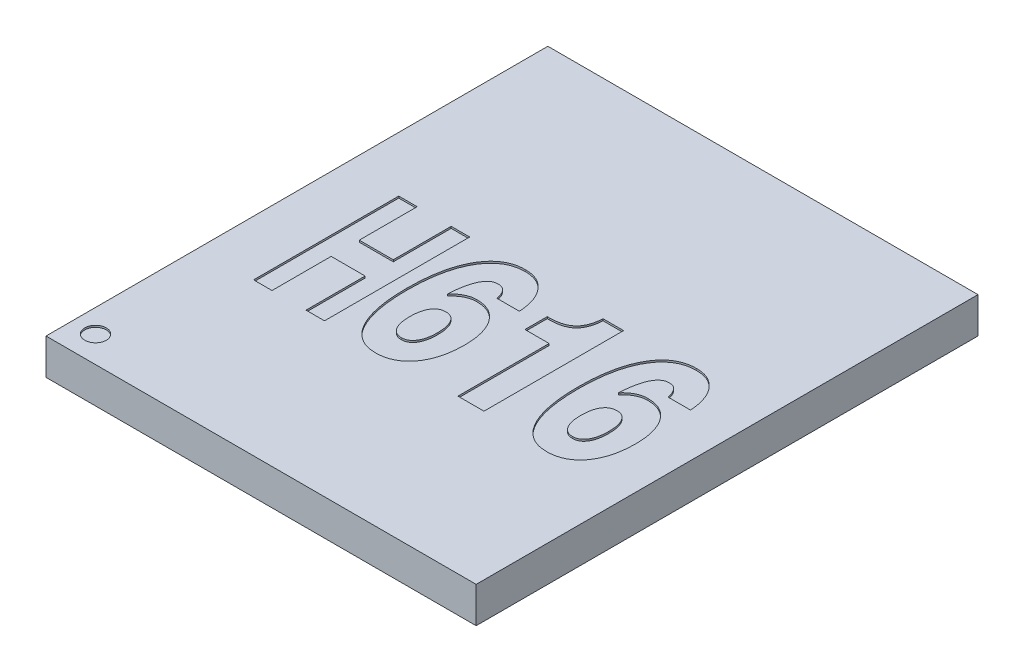
from build123d import *

# Parameters (mm, degrees)
SKETCH1_W           = 12
SKETCH1_H           = 14
BOSS_EXTRUDE1_DEPTH = 1
SKETCH2_R           = 0.175
BOSS_EXTRUDE2_DEPTH = 0.12
FILLET2_R           = 0.08
SKETCH3_R           = 0.3
CUT_EXTRUDE1_DEPTH  = 0.05


with BuildPart() as part:
    # Sketch1 → Boss-Extrude1 (new body)
    with BuildSketch(Plane(origin=(0, 0, 0), x_dir=(1, 0, 0), z_dir=(0, 1, 0))):
        Rectangle(SKETCH1_W, SKETCH1_H)
    extrude(amount=BOSS_EXTRUDE1_DEPTH)

    # Sketch2 → Boss-Extrude2 (add)
    with BuildSketch(Plane.XZ):
        with Locations((5.5, -6.525)):
            Circle(SKETCH2_R)
        with Locations((-5.5, -6.525)):
            Circle(SKETCH2_R)
        with Locations((4.85, -6.525)):
            Circle(SKETCH2_R)
        with Locations((4.2, -6.525)):
            Circle(SKETCH2_R)
        with Locations((3.55, -6.525)):
            Circle(SKETCH2_R)
        with Locations((2.9, -6.525)):
            Circle(SKETCH2_R)
        with Locations((2.25, -6.525)):
            Circle(SKETCH2_R)
        with Locations((1.6, -6.525)):
            Circle(SKETCH2_R)
        with Locations((0.95, -6.525)):
            Circle(SKETCH2_R)
        with Locations((0.3, -6.525)):
            Circle(SKETCH2_R)
        with Locations((-0.35, -6.525)):
            Circle(SKETCH2_R)
        with Locations((-1, -6.525)):
            Circle(SKETCH2_R)
        with Locations((-1.65, -6.525)):
            Circle(SKETCH2_R)
        with Locations((-2.3, -6.525)):
            Circle(SKETCH2_R)
        with Locations((-2.95, -6.525)):
            Circle(SKETCH2_R)
        with Locations((-3.6, -6.525)):
            Circle(SKETCH2_R)
        with Locations((-4.25, -6.525)):
            Circle(SKETCH2_R)
        with Locations((-4.9, -6.525)):
            Circle(SKETCH2_R)
        with Locations((4.85, -5.875)):
            Circle(SKETCH2_R)
        with Locations((4.2, -5.875)):
            Circle(SKETCH2_R)
        with Locations((3.55, -5.875)):
            Circle(SKETCH2_R)
        with Locations((2.9, -5.875)):
            Circle(SKETCH2_R)
        with Locations((2.25, -5.875)):
            Circle(SKETCH2_R)
        with Locations((1.6, -5.875)):
            Circle(SKETCH2_R)
        with Locations((0.95, -5.875)):
            Circle(SKETCH2_R)
        with Locations((0.3, -5.875)):
            Circle(SKETCH2_R)
        with Locations((-0.35, -5.875)):
            Circle(SKETCH2_R)
        with Locations((-1, -5.875)):
            Circle(SKETCH2_R)
        with Locations((-1.65, -5.875)):
            Circle(SKETCH2_R)
        with Locations((-2.3, -5.875)):
            Circle(SKETCH2_R)
        with Locations((-2.95, -5.875)):
            Circle(SKETCH2_R)
        with Locations((-3.6, -5.875)):
            Circle(SKETCH2_R)
        with Locations((-4.25, -5.875)):
            Circle(SKETCH2_R)
        with Locations((-4.9, -5.875)):
            Circle(SKETCH2_R)
        with Locations((-5.55, -5.875)):
            Circle(SKETCH2_R)
        with Locations((4.85, -5.225)):
            Circle(SKETCH2_R)
        with Locations((-4.9, -5.225)):
            Circle(SKETCH2_R)
        with Locations((-5.55, -5.225)):
            Circle(SKETCH2_R)
        with Locations((4.85, -4.575)):
            Circle(SKETCH2_R)
        with Locations((-4.9, -4.575)):
            Circle(SKETCH2_R)
        with Locations((-5.55, -4.575)):
            Circle(SKETCH2_R)
        with Locations((4.85, -3.925)):
            Circle(SKETCH2_R)
        with Locations((-4.9, -3.925)):
            Circle(SKETCH2_R)
        with Locations((-5.55, -3.925)):
            Circle(SKETCH2_R)
        with Locations((4.85, -3.275)):
            Circle(SKETCH2_R)
        with Locations((-4.9, -3.275)):
            Circle(SKETCH2_R)
        with Locations((-5.55, -3.275)):
            Circle(SKETCH2_R)
        with Locations((4.85, -2.625)):
            Circle(SKETCH2_R)
        with Locations((-4.9, -2.625)):
            Circle(SKETCH2_R)
        with Locations((-5.55, -2.625)):
            Circle(SKETCH2_R)
        with Locations((4.85, -1.975)):
            Circle(SKETCH2_R)
        with Locations((-4.9, -1.975)):
            Circle(SKETCH2_R)
        with Locations((-5.55, -1.975)):
            Circle(SKETCH2_R)
        with Locations((4.85, -1.325)):
            Circle(SKETCH2_R)
        with Locations((-4.9, -1.325)):
            Circle(SKETCH2_R)
        with Locations((-5.55, -1.325)):
            Circle(SKETCH2_R)
        with Locations((4.85, -0.675)):
            Circle(SKETCH2_R)
        with Locations((-4.9, -0.675)):
            Circle(SKETCH2_R)
        with Locations((-5.55, -0.675)):
            Circle(SKETCH2_R)
        with Locations((4.85, -0.025)):
            Circle(SKETCH2_R)
        with Locations((-4.9, -0.025)):
            Circle(SKETCH2_R)
        with Locations((-5.55, -0.025)):
            Circle(SKETCH2_R)
        with Locations((4.85, 0.625)):
            Circle(SKETCH2_R)
        with Locations((-4.9, 0.625)):
            Circle(SKETCH2_R)
        with Locations((-5.55, 0.625)):
            Circle(SKETCH2_R)
        with Locations((4.85, 1.275)):
            Circle(SKETCH2_R)
        with Locations((-4.9, 1.275)):
            Circle(SKETCH2_R)
        with Locations((-5.55, 1.275)):
            Circle(SKETCH2_R)
        with Locations((4.85, 1.925)):
            Circle(SKETCH2_R)
        with Locations((-4.9, 1.925)):
            Circle(SKETCH2_R)
        with Locations((-5.55, 1.925)):
            Circle(SKETCH2_R)
        with Locations((4.85, 2.575)):
            Circle(SKETCH2_R)
        with Locations((-4.9, 2.575)):
            Circle(SKETCH2_R)
        with Locations((-5.55, 2.575)):
            Circle(SKETCH2_R)
        with Locations((4.85, 3.225)):
            Circle(SKETCH2_R)
        with Locations((-4.9, 3.225)):
            Circle(SKETCH2_R)
        with Locations((-5.55, 3.225)):
            Circle(SKETCH2_R)
        with Locations((4.85, 3.875)):
            Circle(SKETCH2_R)
        with Locations((-4.9, 3.875)):
            Circle(SKETCH2_R)
        with Locations((-5.55, 3.875)):
            Circle(SKETCH2_R)
        with Locations((4.85, 4.525)):
            Circle(SKETCH2_R)
        with Locations((-4.9, 4.525)):
            Circle(SKETCH2_R)
        with Locations((-5.55, 4.525)):
            Circle(SKETCH2_R)
        with Locations((4.85, 5.175)):
            Circle(SKETCH2_R)
        with Locations((-4.9, 5.175)):
            Circle(SKETCH2_R)
        with Locations((-5.55, 5.175)):
            Circle(SKETCH2_R)
        with Locations((4.85, 5.825)):
            Circle(SKETCH2_R)
        with Locations((4.2, 5.825)):
            Circle(SKETCH2_R)
        with Locations((3.55, 5.825)):
            Circle(SKETCH2_R)
        with Locations((2.9, 5.825)):
            Circle(SKETCH2_R)
        with Locations((2.25, 5.825)):
            Circle(SKETCH2_R)
        with Locations((1.6, 5.825)):
            Circle(SKETCH2_R)
        with Locations((0.95, 5.825)):
            Circle(SKETCH2_R)
        with Locations((0.3, 5.825)):
            Circle(SKETCH2_R)
        with Locations((-0.35, 5.825)):
            Circle(SKETCH2_R)
        with Locations((-1, 5.825)):
            Circle(SKETCH2_R)
        with Locations((-1.65, 5.825)):
            Circle(SKETCH2_R)
        with Locations((-2.3, 5.825)):
            Circle(SKETCH2_R)
        with Locations((-2.95, 5.825)):
            Circle(SKETCH2_R)
        with Locations((-3.6, 5.825)):
            Circle(SKETCH2_R)
        with Locations((-4.25, 5.825)):
            Circle(SKETCH2_R)
        with Locations((-4.9, 5.825)):
            Circle(SKETCH2_R)
        with Locations((-5.55, 5.825)):
            Circle(SKETCH2_R)
        with Locations((4.85, 6.475)):
            Circle(SKETCH2_R)
        with Locations((4.2, 6.475)):
            Circle(SKETCH2_R)
        with Locations((3.55, 6.475)):
            Circle(SKETCH2_R)
        with Locations((2.9, 6.475)):
            Circle(SKETCH2_R)
        with Locations((2.25, 6.475)):
            Circle(SKETCH2_R)
        with Locations((1.6, 6.475)):
            Circle(SKETCH2_R)
        with Locations((0.95, 6.475)):
            Circle(SKETCH2_R)
        with Locations((0.3, 6.475)):
            Circle(SKETCH2_R)
        with Locations((-0.35, 6.475)):
            Circle(SKETCH2_R)
        with Locations((-1, 6.475)):
            Circle(SKETCH2_R)
        with Locations((-1.65, 6.475)):
            Circle(SKETCH2_R)
        with Locations((-2.3, 6.475)):
            Circle(SKETCH2_R)
        with Locations((-2.95, 6.475)):
            Circle(SKETCH2_R)
        with Locations((-3.6, 6.475)):
            Circle(SKETCH2_R)
        with Locations((-4.25, 6.475)):
            Circle(SKETCH2_R)
        with Locations((-4.9, 6.475)):
            Circle(SKETCH2_R)
        with Locations((-5.55, 6.475)):
            Circle(SKETCH2_R)
        with Locations((5.5, -5.875)):
            Circle(SKETCH2_R)
        with Locations((5.5, -5.225)):
            Circle(SKETCH2_R)
        with Locations((5.5, -4.575)):
            Circle(SKETCH2_R)
        with Locations((5.5, -3.925)):
            Circle(SKETCH2_R)
        with Locations((5.5, -3.275)):
            Circle(SKETCH2_R)
        with Locations((5.5, -2.625)):
            Circle(SKETCH2_R)
        with Locations((5.5, -1.975)):
            Circle(SKETCH2_R)
        with Locations((5.5, -1.325)):
            Circle(SKETCH2_R)
        with Locations((5.5, -0.675)):
            Circle(SKETCH2_R)
        with Locations((5.5, -0.025)):
            Circle(SKETCH2_R)
        with Locations((5.5, 0.625)):
            Circle(SKETCH2_R)
        with Locations((5.5, 1.275)):
            Circle(SKETCH2_R)
        with Locations((5.5, 1.925)):
            Circle(SKETCH2_R)
        with Locations((5.5, 2.575)):
            Circle(SKETCH2_R)
        with Locations((5.5, 3.225)):
            Circle(SKETCH2_R)
        with Locations((5.5, 3.875)):
            Circle(SKETCH2_R)
        with Locations((5.5, 4.525)):
            Circle(SKETCH2_R)
        with Locations((5.5, 5.175)):
            Circle(SKETCH2_R)
        with Locations((5.5, 5.825)):
            Circle(SKETCH2_R)
        with Locations((5.5, 6.475)):
            Circle(SKETCH2_R)
    extrude(amount=BOSS_EXTRUDE2_DEPTH)

    # Fillet2
    fillet2_edges = [part.edges().sort_by_distance(p)[0] for p in [
        (-0.525, -0.12, -5.875),
        (-1.175, -0.12, -5.875),
        (-1.825, -0.12, -5.875),
        (-2.475, -0.12, -5.875),
        (-3.125, -0.12, -5.875),
        (-3.775, -0.12, -5.875),
        (-4.425, -0.12, -5.875),
        (-5.075, -0.12, -5.875),
        (-5.725, -0.12, -5.875),
        (4.675, -0.12, -5.225),
        (-5.075, -0.12, -5.225),
        (-5.725, -0.12, -5.225),
        (4.675, -0.12, -4.575),
        (-5.075, -0.12, -4.575),
        (-5.725, -0.12, -4.575),
        (5.325, -0.12, -6.525),
        (4.675, -0.12, -3.925),
        (-5.075, -0.12, -3.925),
        (-5.725, -0.12, -3.925),
        (4.675, -0.12, -3.275),
        (-5.075, -0.12, -3.275),
        (-5.725, -0.12, -3.275),
        (4.675, -0.12, -2.625),
        (-5.075, -0.12, -2.625),
        (-5.725, -0.12, -2.625),
        (4.675, -0.12, -1.975),
        (-5.675, -0.12, -6.525),
        (-5.075, -0.12, -1.975),
        (-5.725, -0.12, -1.975),
        (4.675, -0.12, -1.325),
        (-5.075, -0.12, -1.325),
        (-5.725, -0.12, -1.325),
        (4.675, -0.12, -0.675),
        (-5.075, -0.12, -0.675),
        (-5.725, -0.12, -0.675),
        (4.675, -0.12, -0.025),
        (-5.075, -0.12, -0.025),
        (4.675, -0.12, -6.525),
        (-5.725, -0.12, -0.025),
        (4.675, -0.12, 0.625),
        (-5.075, -0.12, 0.625),
        (-5.725, -0.12, 0.625),
        (4.675, -0.12, 1.275),
        (-5.075, -0.12, 1.275),
        (-5.725, -0.12, 1.275),
        (4.675, -0.12, 1.925),
        (-5.075, -0.12, 1.925),
        (-5.725, -0.12, 1.925),
        (4.025, -0.12, -6.525),
        (4.675, -0.12, 2.575),
        (-5.075, -0.12, 2.575),
        (-5.725, -0.12, 2.575),
        (4.675, -0.12, 3.225),
        (-5.075, -0.12, 3.225),
        (-5.725, -0.12, 3.225),
        (4.675, -0.12, 3.875),
        (-5.075, -0.12, 3.875),
        (-5.725, -0.12, 3.875),
        (4.675, -0.12, 4.525),
        (3.375, -0.12, -6.525),
        (-5.075, -0.12, 4.525),
        (-5.725, -0.12, 4.525),
        (4.675, -0.12, 5.175),
        (-5.075, -0.12, 5.175),
        (-5.725, -0.12, 5.175),
        (4.675, -0.12, 5.825),
        (4.025, -0.12, 5.825),
        (3.375, -0.12, 5.825),
        (2.725, -0.12, 5.825),
        (2.075, -0.12, 5.825),
        (2.725, -0.12, -6.525),
        (1.425, -0.12, 5.825),
        (0.775, -0.12, 5.825),
        (0.125, -0.12, 5.825),
        (-0.525, -0.12, 5.825),
        (-1.175, -0.12, 5.825),
        (-1.825, -0.12, 5.825),
        (-2.475, -0.12, 5.825),
        (-3.125, -0.12, 5.825),
        (-3.775, -0.12, 5.825),
        (-4.425, -0.12, 5.825),
        (2.075, -0.12, -6.525),
        (-5.075, -0.12, 5.825),
        (-5.725, -0.12, 5.825),
        (4.675, -0.12, 6.475),
        (4.025, -0.12, 6.475),
        (3.375, -0.12, 6.475),
        (2.725, -0.12, 6.475),
        (2.075, -0.12, 6.475),
        (1.425, -0.12, 6.475),
        (0.775, -0.12, 6.475),
        (0.125, -0.12, 6.475),
        (1.425, -0.12, -6.525),
        (-0.525, -0.12, 6.475),
        (-1.175, -0.12, 6.475),
        (-1.825, -0.12, 6.475),
        (-2.475, -0.12, 6.475),
        (-3.125, -0.12, 6.475),
        (-3.775, -0.12, 6.475),
        (-4.425, -0.12, 6.475),
        (-5.075, -0.12, 6.475),
        (-5.725, -0.12, 6.475),
        (5.325, -0.12, -5.875),
        (0.775, -0.12, -6.525),
        (5.325, -0.12, -5.225),
        (5.325, -0.12, -4.575),
        (5.325, -0.12, -3.925),
        (5.325, -0.12, -3.275),
        (5.325, -0.12, -2.625),
        (5.325, -0.12, -1.975),
        (5.325, -0.12, -1.325),
        (5.325, -0.12, -0.675),
        (5.325, -0.12, -0.025),
        (5.325, -0.12, 0.625),
        (0.125, -0.12, -6.525),
        (5.325, -0.12, 1.275),
        (5.325, -0.12, 1.925),
        (5.325, -0.12, 2.575),
        (5.325, -0.12, 3.225),
        (5.325, -0.12, 3.875),
        (5.325, -0.12, 4.525),
        (5.325, -0.12, 5.175),
        (5.325, -0.12, 5.825),
        (5.325, -0.12, 6.475),
        (-0.525, -0.12, -6.525),
        (-1.175, -0.12, -6.525),
        (-1.825, -0.12, -6.525),
        (-2.475, -0.12, -6.525),
        (-3.125, -0.12, -6.525),
        (-3.775, -0.12, -6.525),
        (-4.425, -0.12, -6.525),
        (-5.075, -0.12, -6.525),
        (4.675, -0.12, -5.875),
        (4.025, -0.12, -5.875),
        (3.375, -0.12, -5.875),
        (2.725, -0.12, -5.875),
        (2.075, -0.12, -5.875),
        (1.425, -0.12, -5.875),
        (0.775, -0.12, -5.875),
        (0.125, -0.12, -5.875),
    ]]
    fillet(fillet2_edges, radius=FILLET2_R)

    # Sketch3 → Cut-Extrude1 (cut)
    with BuildSketch(Plane(origin=(0, 1, 0), x_dir=(1, 0, 0), z_dir=(0, 1, 0))):
        with Locations((-5.356190636, -6.262008845)):
            Circle(SKETCH3_R)
        Polygon((-2.482005753, -2.74830439), (-2.998297075, -2.74830439), (-2.998297075, -1.0990172), (-3.946365257, -1.0990172), (-3.946365257, -2.74830439), (-4.460983026, -2.74830439), (-4.460983026, 1.30169561), (-3.946365257, 1.30169561), (-3.946365257, -0.314120505), (-2.998297075, -0.314120505), (-2.998297075, 1.30169561), (-2.482005753, 1.30169561), align=None)
        with BuildLine():
            Line((0.006356665, 0.200468167), (-0.616720258, 0.200468167))
            add(Edge.make_bspline(
                [(-0.616720258, 0.200468167), (-0.623726124, 0.22956079), (-0.636944726, 0.284452476), (-0.664264545, 0.359922802), (-0.697450704, 0.423111864), (-0.73583534, 0.474996979), (-0.780671587, 0.514859659), (-0.830877476, 0.544269964), (-0.888044745, 0.5607696), (-0.927884783, 0.562850693), (-0.948541171, 0.563929705)],
                knots=[0, 0, 0, 0, 8.9732e-05, 0.000169305, 0.000240079, 0.000303199, 0.000361815, 0.000418872, 0.000476377, 0.000538296, 0.000538296, 0.000538296, 0.000538296], degree=3))
            add(Edge.make_bspline(
                [(-0.948541171, 0.563929705), (-0.965089948, 0.563036767), (-0.997710129, 0.56127665), (-1.045537101, 0.550648784), (-1.090790464, 0.531972468), (-1.132178291, 0.503952164), (-1.172785342, 0.471273279), (-1.208044654, 0.428361572), (-1.242494996, 0.380004119), (-1.272943756, 0.323291754), (-1.301466416, 0.259977266), (-1.326440857, 0.189091653), (-1.348050031, 0.110910549), (-1.367404793, 0.025610673), (-1.384510726, -0.066907543), (-1.39812802, -0.166814748), (-1.408499212, -0.274013409), (-1.413347572, -0.347954028), (-1.415848864, -0.386100343)],
                knots=[0, 0, 0, 0, 4.9655e-05, 9.7878e-05, 0.000146244, 0.000195526, 0.000247361, 0.000302008, 0.000361426, 0.000425334, 0.000494694, 0.000569624, 0.00065053, 0.000737913, 0.000831958, 0.000932696, 0.001040305, 0.001154986, 0.001154986, 0.001154986, 0.001154986], degree=3))
            add(Edge.make_bspline(
                [(-1.415848864, -0.386100343), (-1.395453838, -0.364027849), (-1.355653891, -0.320954401), (-1.290412315, -0.265379543), (-1.224554675, -0.217505618), (-1.156637551, -0.179218328), (-1.087133322, -0.148708646), (-1.015847854, -0.126874673), (-0.942846736, -0.113188252), (-0.893702322, -0.11177812), (-0.86903396, -0.111070295)],
                knots=[0, 0, 0, 0, 9.0083e-05, 0.000175793, 0.000256618, 0.000334003, 0.000409213, 0.000483892, 0.000557255, 0.000631195, 0.000631195, 0.000631195, 0.000631195], degree=3))
            add(Edge.make_bspline(
                [(-0.86903396, -0.111070295), (-0.834097284, -0.112262242), (-0.765770554, -0.114593369), (-0.665949305, -0.129882366), (-0.572026473, -0.156899745), (-0.483662332, -0.194381844), (-0.40113035, -0.242715119), (-0.32403409, -0.301601321), (-0.253681785, -0.37203055), (-0.188484903, -0.451784887), (-0.130442988, -0.540795508), (-0.080013868, -0.638218783), (-0.036779759, -0.743181363), (-0.002434002, -0.856347604), (0.025443623, -0.976902748), (0.044574111, -1.10548126), (0.055872028, -1.241815418), (0.057464138, -1.335297042), (0.058279742, -1.38318568)],
                knots=[0, 0, 0, 0, 0.000104811, 0.000204983, 0.000302048, 0.000397284, 0.000492182, 0.000588245, 0.000687492, 0.000790127, 0.000896787, 0.001005649, 0.001118795, 0.001236839, 0.001360038, 0.001489694, 0.001626464, 0.001770122, 0.001770122, 0.001770122, 0.001770122], degree=3))
            add(Edge.make_bspline(
                [(0.058279742, -1.38318568), (0.057718803, -1.437039298), (0.056628743, -1.541691733), (0.041895799, -1.694427622), (0.020817565, -1.838485934), (-0.009935284, -1.974262524), (-0.05043355, -2.100644304), (-0.099532641, -2.218706789), (-0.156532615, -2.328428163), (-0.223596866, -2.428211013), (-0.296511433, -2.518614701), (-0.378210725, -2.596468645), (-0.465373568, -2.663441941), (-0.560073587, -2.717225649), (-0.660251207, -2.760322814), (-0.767804251, -2.788505257), (-0.880999114, -2.808546032), (-0.95899432, -2.810216739), (-0.998841652, -2.811070295)],
                knots=[0, 0, 0, 0, 0.000161499, 0.000313838, 0.000459901, 0.00059806, 0.000730964, 0.000857527, 0.000981275, 0.001101208, 0.001217657, 0.001328973, 0.001438987, 0.00154656, 0.001654901, 0.001765121, 0.001879425, 0.001998821, 0.001998821, 0.001998821, 0.001998821], degree=3))
            add(Edge.make_bspline(
                [(-0.998841652, -2.811070295), (-1.042773607, -2.809601048), (-1.128641027, -2.806729323), (-1.253197248, -2.78162251), (-1.370174163, -2.74105961), (-1.478708495, -2.682365806), (-1.580302305, -2.608856589), (-1.673677538, -2.518430248), (-1.757641713, -2.41094284), (-1.835057911, -2.28890032), (-1.902816002, -2.15103792), (-1.96167315, -1.9988864), (-2.012067548, -1.83296744), (-2.051766429, -1.652967289), (-2.084522136, -1.459718927), (-2.106800668, -1.25219805), (-2.119453173, -1.030701425), (-2.121457708, -0.878304532), (-2.122489489, -0.799862362)],
                knots=[0, 0, 0, 0, 0.00013168, 0.000257377, 0.000379514, 0.000501829, 0.000626135, 0.000754659, 0.000890359, 0.001034408, 0.001187519, 0.001350382, 0.001523362, 0.00170719, 0.001902987, 0.002111112, 0.002332976, 0.002568303, 0.002568303, 0.002568303, 0.002568303], degree=3))
            add(Edge.make_bspline(
                [(-2.122489489, -0.799862362), (-2.121589893, -0.719251934), (-2.119840455, -0.562489302), (-2.105324233, -0.334192887), (-2.080406245, -0.119695624), (-2.045574834, 0.080708383), (-2.00253363, 0.267244719), (-1.948071084, 0.439559101), (-1.883264876, 0.597645341), (-1.809971902, 0.742216071), (-1.726383321, 0.870298092), (-1.635480084, 0.983178847), (-1.535023012, 1.077737363), (-1.426926948, 1.156385702), (-1.309941214, 1.216540254), (-1.185042772, 1.260345303), (-1.051769875, 1.285499813), (-0.960273234, 1.289045991), (-0.913655354, 1.290852782)],
                knots=[0, 0, 0, 0, 0.000241816, 0.000470258, 0.000685912, 0.000889317, 0.001080199, 0.001259806, 0.001430805, 0.001592272, 0.001745289, 0.001888853, 0.00202602, 0.002157962, 0.002288591, 0.00241919, 0.002553802, 0.00269363, 0.00269363, 0.00269363, 0.00269363], degree=3))
            add(Edge.make_bspline(
                [(-0.913655354, 1.290852782), (-0.881420548, 1.289908697), (-0.818271039, 1.288059188), (-0.725844799, 1.273779558), (-0.638142982, 1.251427989), (-0.555023084, 1.219407997), (-0.476610804, 1.177681793), (-0.403032616, 1.126525844), (-0.333898871, 1.066444478), (-0.27041733, 0.997587019), (-0.211714403, 0.921201331), (-0.160043512, 0.837657497), (-0.11501012, 0.747486846), (-0.077171342, 0.650723237), (-0.045290062, 0.54748771), (-0.021426425, 0.437496276), (-0.00328133, 0.321269883), (0.003094049, 0.241361485), (0.006356665, 0.200468167)],
                knots=[0, 0, 0, 0, 9.6667e-05, 0.000189375, 0.000279892, 0.00036773, 0.000455923, 0.000545717, 0.000636005, 0.000730151, 0.000826213, 0.000924595, 0.001024371, 0.001128173, 0.001235957, 0.001348154, 0.001465534, 0.001588566, 0.001588566, 0.001588566, 0.001588566], degree=3))
        make_face()
        with BuildLine():
            add(Edge.make_bspline(
                [(-1.002898142, -2.084147218), (-0.97421365, -2.082170489), (-0.918040656, -2.078299449), (-0.838862214, -2.045973507), (-0.771318381, -1.991504163), (-0.715410186, -1.917282649), (-0.669790559, -1.825598651), (-0.63955186, -1.716010829), (-0.619742882, -1.590784138), (-0.617766466, -1.5017237), (-0.616720258, -1.45457991)],
                knots=[0, 0, 0, 0, 8.5837e-05, 0.000168095, 0.000251847, 0.000343211, 0.000444801, 0.000557247, 0.000682894, 0.000824209, 0.000824209, 0.000824209, 0.000824209], degree=3))
            add(Edge.make_bspline(
                [(-0.616720258, -1.45457991), (-0.617914751, -1.408277563), (-0.620168133, -1.320929324), (-0.638072741, -1.197677536), (-0.670438238, -1.090974956), (-0.714398547, -1.000519179), (-0.770573659, -0.927954232), (-0.838564394, -0.875567706), (-0.917377971, -0.84265533), (-0.973912593, -0.83957346), (-1.002898142, -0.837993372)],
                knots=[0, 0, 0, 0, 0.000138884, 0.000262001, 0.000372349, 0.000472126, 0.000562213, 0.000644969, 0.000727227, 0.000813774, 0.000813774, 0.000813774, 0.000813774], degree=3))
            add(Edge.make_bspline(
                [(-1.002898142, -0.837993372), (-1.032971681, -0.839511366), (-1.091106113, -0.842445765), (-1.171973677, -0.875541914), (-1.241614271, -0.927613353), (-1.298693214, -1.000304369), (-1.342983584, -1.091074663), (-1.374096236, -1.199187144), (-1.392123782, -1.323898648), (-1.39437658, -1.412599629), (-1.395566412, -1.459447699)],
                knots=[0, 0, 0, 0, 8.9772e-05, 0.000173537, 0.000257587, 0.000348181, 0.000447957, 0.000558847, 0.00068437, 0.000824875, 0.000824875, 0.000824875, 0.000824875], degree=3))
            add(Edge.make_bspline(
                [(-1.395566412, -1.459447699), (-1.394470988, -1.506037978), (-1.392396581, -1.594266124), (-1.373093981, -1.718653569), (-1.341225477, -1.827250636), (-1.296410516, -1.919029634), (-1.239213894, -1.992794077), (-1.169970837, -2.045693392), (-1.089707798, -2.078585791), (-1.032419207, -2.082255962), (-1.002898142, -2.084147218)],
                knots=[0, 0, 0, 0, 0.000139694, 0.000264539, 0.000376439, 0.00047803, 0.000569257, 0.000653796, 0.000736806, 0.000825059, 0.000825059, 0.000825059, 0.000825059], degree=3))
        make_face(mode=Mode.SUBTRACT)
        with BuildLine():
            Line((1.198510511, -2.707224141), (1.198510511, -0.162993372))
            Line((1.198510511, -0.162993372), (0.523510511, -0.162993372))
            Line((0.523510511, -0.162993372), (0.523510511, 0.460083551))
            Line((0.523510511, 0.460083551), (0.582735271, 0.460083551))
            add(Edge.make_bspline(
                [(0.582735271, 0.460083551), (0.613312573, 0.460457396), (0.672420924, 0.461180069), (0.758133904, 0.469367911), (0.837559582, 0.483114448), (0.911266311, 0.501548224), (0.9790309, 0.525858207), (1.040693278, 0.555895028), (1.096704359, 0.590683997), (1.145758766, 0.632188086), (1.190610776, 0.678518306), (1.22802144, 0.73300871), (1.263062128, 0.792344489), (1.290688718, 0.859257901), (1.314379718, 0.931918069), (1.333181218, 1.011098939), (1.345572687, 1.096949341), (1.350786658, 1.156418761), (1.353468444, 1.187006628)],
                knots=[0, 0, 0, 0, 9.1709e-05, 0.000177281, 0.000257975, 0.000333339, 0.00040494, 0.000473518, 0.000538791, 0.000602155, 0.000665856, 0.000731591, 0.000799919, 0.000872252, 0.000948194, 0.001029072, 0.001116043, 0.001208153, 0.001208153, 0.001208153, 0.001208153], degree=3))
            Line((1.353468444, 1.187006628), (1.925433588, 1.187006628))
            Line((1.925433588, 1.187006628), (1.925433588, -2.707224141))
            Line((1.925433588, -2.707224141), (1.198510511, -2.707224141))
        make_face()
        with BuildLine():
            Line((4.779125896, 0.200468167), (4.156048973, 0.200468167))
            add(Edge.make_bspline(
                [(4.156048973, 0.200468167), (4.149043107, 0.22956079), (4.135824505, 0.284452476), (4.108504686, 0.359922802), (4.075318527, 0.423111864), (4.036933891, 0.474996979), (3.992097644, 0.514859659), (3.941891754, 0.544269964), (3.884724486, 0.5607696), (3.844884448, 0.562850693), (3.82422806, 0.563929705)],
                knots=[0, 0, 0, 0, 8.9732e-05, 0.000169305, 0.000240079, 0.000303199, 0.000361815, 0.000418872, 0.000476377, 0.000538296, 0.000538296, 0.000538296, 0.000538296], degree=3))
            add(Edge.make_bspline(
                [(3.82422806, 0.563929705), (3.807679283, 0.563036767), (3.775059102, 0.56127665), (3.72723213, 0.550648784), (3.681978766, 0.531972468), (3.64059094, 0.503952164), (3.599983888, 0.471273279), (3.564724577, 0.428361572), (3.530274235, 0.380004119), (3.499825474, 0.323291754), (3.471302815, 0.259977266), (3.446328373, 0.189091653), (3.424719199, 0.110910549), (3.405364437, 0.025610673), (3.388258505, -0.066907543), (3.374641211, -0.166814748), (3.364270019, -0.274013409), (3.359421659, -0.347954028), (3.356920367, -0.386100343)],
                knots=[0, 0, 0, 0, 4.9655e-05, 9.7878e-05, 0.000146244, 0.000195526, 0.000247361, 0.000302008, 0.000361426, 0.000425334, 0.000494694, 0.000569624, 0.00065053, 0.000737913, 0.000831958, 0.000932696, 0.001040305, 0.001154986, 0.001154986, 0.001154986, 0.001154986], degree=3))
            add(Edge.make_bspline(
                [(3.356920367, -0.386100343), (3.377315393, -0.364027849), (3.417115339, -0.320954401), (3.482356916, -0.265379543), (3.548214556, -0.217505618), (3.61613168, -0.179218328), (3.685635909, -0.148708646), (3.756921377, -0.126874673), (3.829922494, -0.113188252), (3.879066909, -0.11177812), (3.903735271, -0.111070295)],
                knots=[0, 0, 0, 0, 9.0083e-05, 0.000175793, 0.000256618, 0.000334003, 0.000409213, 0.000483892, 0.000557255, 0.000631195, 0.000631195, 0.000631195, 0.000631195], degree=3))
            add(Edge.make_bspline(
                [(3.903735271, -0.111070295), (3.938671947, -0.112262242), (4.006998677, -0.114593369), (4.106819926, -0.129882366), (4.200742758, -0.156899745), (4.289106899, -0.194381844), (4.371638881, -0.242715119), (4.448735141, -0.301601321), (4.519087446, -0.37203055), (4.584284328, -0.451784887), (4.642326242, -0.540795508), (4.692755363, -0.638218783), (4.735989472, -0.743181363), (4.770335228, -0.856347604), (4.798212854, -0.976902748), (4.817343342, -1.10548126), (4.828641259, -1.241815418), (4.830233369, -1.335297042), (4.831048973, -1.38318568)],
                knots=[0, 0, 0, 0, 0.000104811, 0.000204983, 0.000302048, 0.000397284, 0.000492182, 0.000588245, 0.000687492, 0.000790127, 0.000896787, 0.001005649, 0.001118795, 0.001236839, 0.001360038, 0.001489694, 0.001626464, 0.001770122, 0.001770122, 0.001770122, 0.001770122], degree=3))
            add(Edge.make_bspline(
                [(4.831048973, -1.38318568), (4.830488034, -1.437039298), (4.829397974, -1.541691733), (4.81466503, -1.694427622), (4.793586796, -1.838485934), (4.762833947, -1.974262524), (4.72233568, -2.100644304), (4.673236589, -2.218706789), (4.616236615, -2.328428163), (4.549172364, -2.428211013), (4.476257798, -2.518614701), (4.394558506, -2.596468645), (4.307395662, -2.663441941), (4.212695644, -2.717225649), (4.112518024, -2.760322814), (4.00496498, -2.788505257), (3.891770117, -2.808546032), (3.813774911, -2.810216739), (3.773927579, -2.811070295)],
                knots=[0, 0, 0, 0, 0.000161499, 0.000313838, 0.000459901, 0.00059806, 0.000730964, 0.000857527, 0.000981275, 0.001101208, 0.001217657, 0.001328973, 0.001438987, 0.00154656, 0.001654901, 0.001765121, 0.001879425, 0.001998821, 0.001998821, 0.001998821, 0.001998821], degree=3))
            add(Edge.make_bspline(
                [(3.773927579, -2.811070295), (3.729995624, -2.809601048), (3.644128204, -2.806729323), (3.519571983, -2.78162251), (3.402595067, -2.74105961), (3.294060736, -2.682365806), (3.192466925, -2.608856589), (3.099091693, -2.518430248), (3.015127518, -2.41094284), (2.93771132, -2.28890032), (2.869953229, -2.15103792), (2.811096081, -1.9988864), (2.760701683, -1.83296744), (2.721002802, -1.652967289), (2.688247095, -1.459718927), (2.665968563, -1.25219805), (2.653316058, -1.030701425), (2.651311522, -0.878304532), (2.650279742, -0.799862362)],
                knots=[0, 0, 0, 0, 0.00013168, 0.000257377, 0.000379514, 0.000501829, 0.000626135, 0.000754659, 0.000890359, 0.001034408, 0.001187519, 0.001350382, 0.001523362, 0.00170719, 0.001902987, 0.002111112, 0.002332976, 0.002568303, 0.002568303, 0.002568303, 0.002568303], degree=3))
            add(Edge.make_bspline(
                [(2.650279742, -0.799862362), (2.651179338, -0.719251934), (2.652928775, -0.562489302), (2.667444998, -0.334192887), (2.692362986, -0.119695624), (2.727194397, 0.080708383), (2.7702356, 0.267244719), (2.824698146, 0.439559101), (2.889504355, 0.597645341), (2.962797329, 0.742216071), (3.046385909, 0.870298092), (3.137289147, 0.983178847), (3.237746219, 1.077737363), (3.345842283, 1.156385702), (3.462828017, 1.216540254), (3.587726459, 1.260345303), (3.720999356, 1.285499813), (3.812495996, 1.289045991), (3.859113877, 1.290852782)],
                knots=[0, 0, 0, 0, 0.000241816, 0.000470258, 0.000685912, 0.000889317, 0.001080199, 0.001259806, 0.001430805, 0.001592272, 0.001745289, 0.001888853, 0.00202602, 0.002157962, 0.002288591, 0.00241919, 0.002553802, 0.00269363, 0.00269363, 0.00269363, 0.00269363], degree=3))
            add(Edge.make_bspline(
                [(3.859113877, 1.290852782), (3.891348682, 1.289908697), (3.954498192, 1.288059188), (4.046924432, 1.273779558), (4.134626248, 1.251427989), (4.217746147, 1.219407997), (4.296158427, 1.177681793), (4.369736615, 1.126525844), (4.43887036, 1.066444478), (4.502351901, 0.997587019), (4.561054827, 0.921201331), (4.612725719, 0.837657497), (4.657759111, 0.747486846), (4.695597889, 0.650723237), (4.727479168, 0.54748771), (4.751342805, 0.437496276), (4.7694879, 0.321269883), (4.77586328, 0.241361485), (4.779125896, 0.200468167)],
                knots=[0, 0, 0, 0, 9.6667e-05, 0.000189375, 0.000279892, 0.00036773, 0.000455923, 0.000545717, 0.000636005, 0.000730151, 0.000826213, 0.000924595, 0.001024371, 0.001128173, 0.001235957, 0.001348154, 0.001465534, 0.001588566, 0.001588566, 0.001588566, 0.001588566], degree=3))
        make_face()
        with BuildLine():
            add(Edge.make_bspline(
                [(3.769871088, -2.084147218), (3.798555581, -2.082170489), (3.854728574, -2.078299449), (3.933907017, -2.045973507), (4.001450849, -1.991504163), (4.057359045, -1.917282649), (4.102978672, -1.825598651), (4.133217371, -1.716010829), (4.153026349, -1.590784138), (4.155002765, -1.5017237), (4.156048973, -1.45457991)],
                knots=[0, 0, 0, 0, 8.5837e-05, 0.000168095, 0.000251847, 0.000343211, 0.000444801, 0.000557247, 0.000682894, 0.000824209, 0.000824209, 0.000824209, 0.000824209], degree=3))
            add(Edge.make_bspline(
                [(4.156048973, -1.45457991), (4.15485448, -1.408277563), (4.152601097, -1.320929324), (4.134696489, -1.197677536), (4.102330993, -1.090974956), (4.058370684, -1.000519179), (4.002195572, -0.927954232), (3.934204837, -0.875567706), (3.855391259, -0.84265533), (3.798856638, -0.83957346), (3.769871088, -0.837993372)],
                knots=[0, 0, 0, 0, 0.000138884, 0.000262001, 0.000372349, 0.000472126, 0.000562213, 0.000644969, 0.000727227, 0.000813774, 0.000813774, 0.000813774, 0.000813774], degree=3))
            add(Edge.make_bspline(
                [(3.769871088, -0.837993372), (3.739797549, -0.839511366), (3.681663118, -0.842445765), (3.600795554, -0.875541914), (3.53115496, -0.927613353), (3.474076017, -1.000304369), (3.429785647, -1.091074663), (3.398672995, -1.199187144), (3.380645449, -1.323898648), (3.378392651, -1.412599629), (3.377202819, -1.459447699)],
                knots=[0, 0, 0, 0, 8.9772e-05, 0.000173537, 0.000257587, 0.000348181, 0.000447957, 0.000558847, 0.00068437, 0.000824875, 0.000824875, 0.000824875, 0.000824875], degree=3))
            add(Edge.make_bspline(
                [(3.377202819, -1.459447699), (3.378298243, -1.506037978), (3.38037265, -1.594266124), (3.39967525, -1.718653569), (3.431543753, -1.827250636), (3.476358715, -1.919029634), (3.533555337, -1.992794077), (3.602798394, -2.045693392), (3.683061433, -2.078585791), (3.740350024, -2.082255962), (3.769871088, -2.084147218)],
                knots=[0, 0, 0, 0, 0.000139694, 0.000264539, 0.000376439, 0.00047803, 0.000569257, 0.000653796, 0.000736806, 0.000825059, 0.000825059, 0.000825059, 0.000825059], degree=3))
        make_face(mode=Mode.SUBTRACT)
    extrude(amount=-CUT_EXTRUDE1_DEPTH, mode=Mode.SUBTRACT)


solid = part.part
